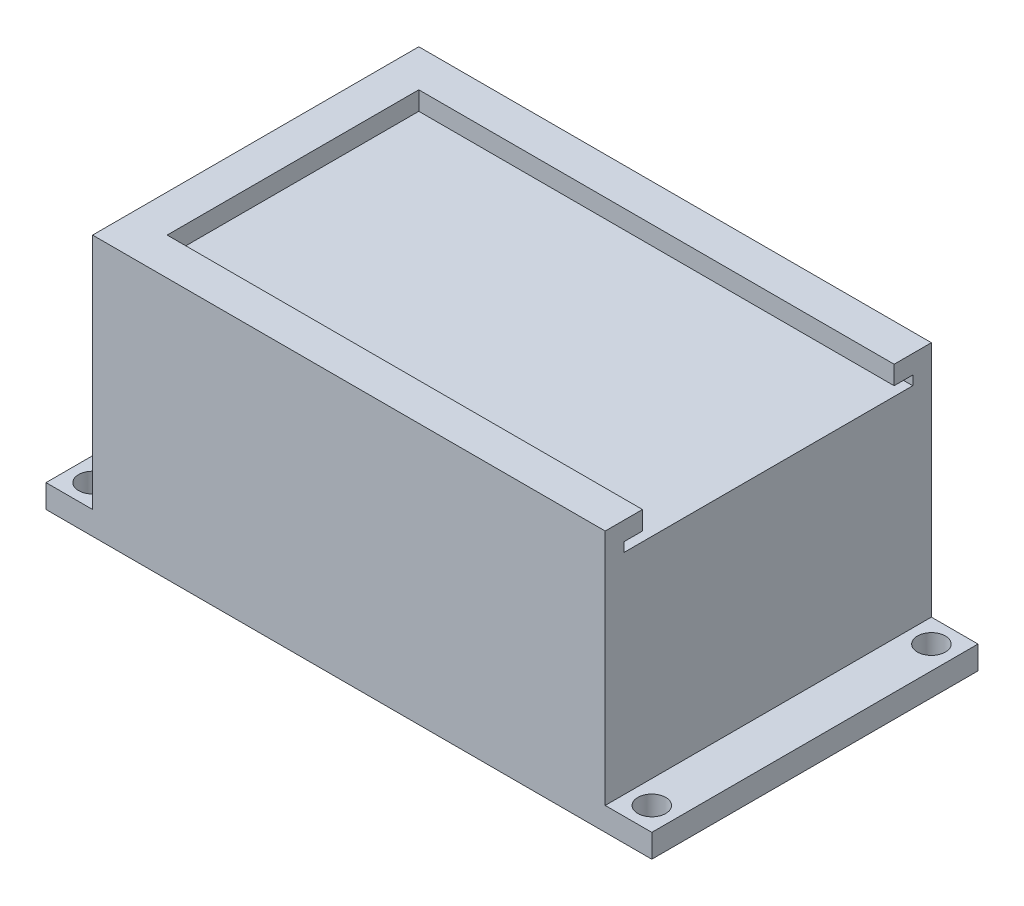
from build123d import *

# Parameters (mm, degrees)
SKETCH1_W           = 165.1
SKETCH1_H           = 88.9
SKETCH1_R           = 3.81
BOSS_EXTRUDE1_DEPTH = 6.35
SKETCH2_W           = 139.7
SKETCH2_H           = 88.9
BOSS_EXTRUDE2_DEPTH = 57.15
SKETCH3_W           = 114.3
SKETCH3_H           = 63.5
CUT_EXTRUDE1_DEPTH  = 50.8
BOSS_EXTRUDE3_DEPTH = 2.54
BOSS_EXTRUDE4_DEPTH = 5.08


with BuildPart() as part:
    # Sketch1 → Boss-Extrude1 (new body)
    with BuildSketch(Plane(origin=(0, 0, 0), x_dir=(1, 0, 0), z_dir=(0, 1, 0))):
        with Locations((-82.55, 44.45)):
            Rectangle(SKETCH1_W, SKETCH1_H)
        with Locations((-158.75, 6.35)):
            Circle(SKETCH1_R, mode=Mode.SUBTRACT)
        with Locations((-158.75, 82.55)):
            Circle(SKETCH1_R, mode=Mode.SUBTRACT)
        with Locations((-6.35, 82.55)):
            Circle(SKETCH1_R, mode=Mode.SUBTRACT)
        with Locations((-6.35, 6.35)):
            Circle(SKETCH1_R, mode=Mode.SUBTRACT)
    extrude(amount=BOSS_EXTRUDE1_DEPTH)

    # Sketch2 → Boss-Extrude2 (add)
    with BuildSketch(Plane(origin=(0, 6.35, 0), x_dir=(1, 0, 0), z_dir=(0, 1, 0))):
        with Locations((-82.55, 44.45)):
            Rectangle(SKETCH2_W, SKETCH2_H)
    extrude(amount=BOSS_EXTRUDE2_DEPTH)

    # Sketch3 → Cut-Extrude1 (cut)
    with BuildSketch(Plane(origin=(0, 0, 0), x_dir=(-1, 0, 0), z_dir=(0, -1, 0))):
        with Locations((82.55, 44.45)):
            Rectangle(SKETCH3_W, SKETCH3_H)
    extrude(amount=-CUT_EXTRUDE1_DEPTH, mode=Mode.SUBTRACT)

    # Sketch5 → Boss-Extrude3 (add)
    with BuildSketch(Plane(origin=(0, 63.5, 0), x_dir=(1, 0, 0), z_dir=(0, 1, 0))):
        Polygon((-152.4, 88.9), (-152.4, 0), (-12.7, 0), (-12.7, 5.08), (-147.32, 5.08), (-147.32, 83.82), (-12.7, 83.82), (-12.7, 88.9), align=None)
    extrude(amount=BOSS_EXTRUDE3_DEPTH)

    # Sketch6 → Boss-Extrude4 (add)
    with BuildSketch(Plane(origin=(0, 66.04, 0), x_dir=(1, 0, 0), z_dir=(0, 1, 0))):
        Polygon((-147.32, 5.08), (-12.7, 5.08), (-12.7, 10.16), (-142.24, 10.16), (-142.24, 78.74), (-12.7, 78.74), (-12.7, 83.82), (-147.32, 83.82), align=None)
        Polygon((-12.7, 5.08), (-147.32, 5.08), (-147.32, 83.82), (-12.7, 83.82), (-12.7, 88.9), (-152.4, 88.9), (-152.4, 0), (-12.7, 0), align=None)
    extrude(amount=BOSS_EXTRUDE4_DEPTH)


solid = part.part
